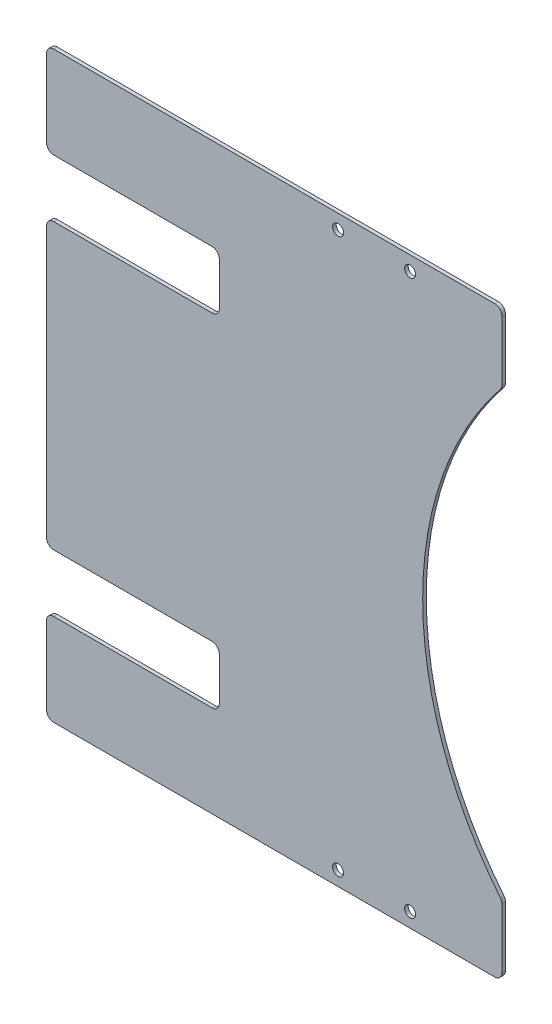
from build123d import *

# Parameters (mm, degrees)
SKETCH_1_W          = 80.5
SKETCH_1_H          = 162
SKETCH_1_R          = 1.525
EXTRUDE_1_DEPTH     = 1
SKETCH_2_R          = 97.5
CUT_EXTRUDE_1_DEPTH = 1
FILLET_1_R          = 2
EXTRUDE_2_DEPTH     = 1
FILLET_2_R          = 2
CUT_EXTRUDE_2_DEPTH = 10
FILLET_3_R          = 2


with BuildPart() as part:
    # 草图1 → 凸台-拉伸1 (new body)
    with BuildSketch(Plane.XY):
        with Locations((-4.75, 0)):
            Rectangle(SKETCH_1_W, SKETCH_1_H)
        with Locations((-10, 77)):
            Circle(SKETCH_1_R, mode=Mode.SUBTRACT)
        with Locations((10, 77)):
            Circle(SKETCH_1_R, mode=Mode.SUBTRACT)
        with Locations((-10, -77)):
            Circle(SKETCH_1_R, mode=Mode.SUBTRACT)
        with Locations((10, -77)):
            Circle(SKETCH_1_R, mode=Mode.SUBTRACT)
    extrude(amount=EXTRUDE_1_DEPTH)

    # 草图2 → 切除-拉伸1 (cut)
    with BuildSketch(Plane(origin=(0, 0, 0), x_dir=(-1, 0, 0), z_dir=(0, 0, -1))):
        with Locations((-111, 0)):
            Circle(SKETCH_2_R)
    extrude(amount=-CUT_EXTRUDE_1_DEPTH, mode=Mode.SUBTRACT)

    # 圆角1
    fillet_1_edges = [part.edges().sort_by_distance(p)[0] for p in [
        (35.5, -61.692787261, 0.5),
        (35.5, 61.692787261, 0.5),
        (35.5, -81, 0.5),
        (-45, -81, 0.5),
        (-45, 81, 0.5),
        (35.5, 81, 0.5),
    ]]
    fillet(fillet_1_edges, radius=FILLET_1_R)

    # 草图3 → 凸台-拉伸2 (add)
    with BuildSketch(Plane.XY.offset(1)):
        Polygon((-91, 81), (-91, 55.5), (-45, 55.5), (-45, 39.5), (-91, 39.5), (-91, -39.5), (-45, -39.5), (-45, -55.5), (-91, -55.5), (-91, -81), (-43, -81), (-43, 81), align=None)
    extrude(amount=-EXTRUDE_2_DEPTH)

    # 圆角2
    fillet_2_edges = [part.edges().sort_by_distance(p)[0] for p in [
        (-91, -81, 0.5),
        (-45, -55.5, 0.5),
        (-91, -55.5, 0.5),
        (-91, 55.5, 0.5),
        (-45, 55.5, 0.5),
        (-91, 81, 0.5),
        (-45, -39.5, 0.5),
        (-45, 39.5, 0.5),
        (-91, 39.5, 0.5),
        (-91, -39.5, 0.5),
    ]]
    fillet(fillet_2_edges, radius=FILLET_2_R)

    # 草图4 → 切除-拉伸2 (cut)
    with BuildSketch(Plane.XY.offset(1)):
        with BuildLine():
            Line((-47, 55.5), (-43, 55.5))
            Line((-43, 55.5), (-43, 39.5))
            Line((-43, 39.5), (-47, 39.5))
            ThreePointArc((-47, 39.5), (-45.585786438, 40.085786438), (-45, 41.5))
            Line((-45, 41.5), (-45, 53.5))
            ThreePointArc((-45, 53.5), (-45.585786438, 54.914213562), (-47, 55.5))
        make_face()
        with BuildLine():
            Line((-47, -39.5), (-43, -39.5))
            Line((-43, -39.5), (-43, -55.5))
            Line((-43, -55.5), (-47, -55.5))
            ThreePointArc((-47, -55.5), (-45.585786438, -54.914213562), (-45, -53.5))
            Line((-45, -53.5), (-45, -41.5))
            ThreePointArc((-45, -41.5), (-45.585786438, -40.085786438), (-47, -39.5))
        make_face()
    extrude(amount=-CUT_EXTRUDE_2_DEPTH, mode=Mode.SUBTRACT)

    # 圆角3
    fillet_3_edges = [part.edges().sort_by_distance(p)[0] for p in [
        (-43, 55.5, 0.5),
        (-43, 39.5, 0.5),
        (-43, -39.5, 0.5),
        (-43, -55.5, 0.5),
    ]]
    fillet(fillet_3_edges, radius=FILLET_3_R)


solid = part.part
